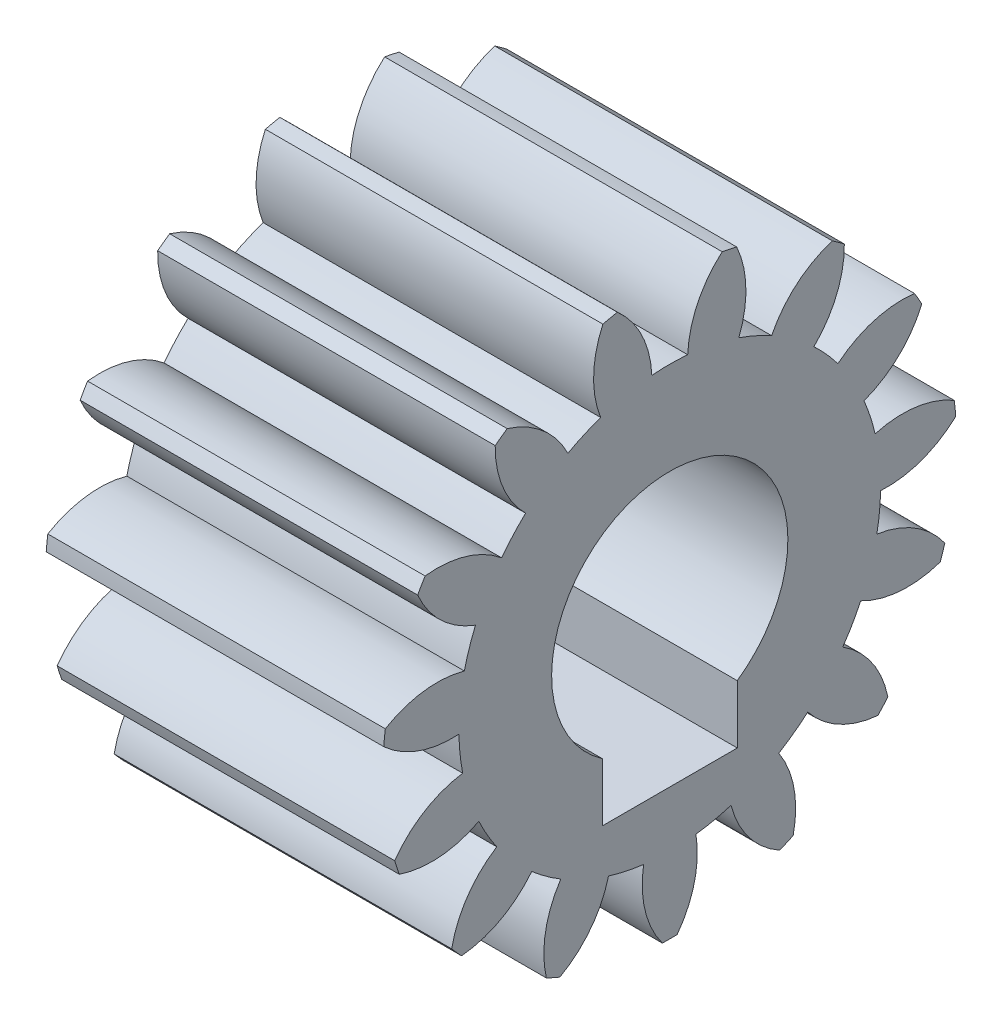
from build123d import *

# Parameters (mm, degrees)
BASPROSKE_W             = 5
BASPROSKE_H             = 4.25
TOOTHCUT_DEPTH          = 8.818247886
TEETHCUTS_COUNT         = 15
TEETHCUTS_ANGLE         = 336
BORSKE_R                = 0.5
BORE_DEPTH              = 50.0000508
SKETCH1_R               = 1.75
CUT_EXTRUDE1_DEPTH      = 8.811066965
CUT_EXTRUDE1_DEPTH_BACK = 8.811066965
SKETCH2_W               = 2
SKETCH2_H               = 1.1
CUT_EXTRUDE2_DEPTH      = 8.811066965
CUT_EXTRUDE2_DEPTH_BACK = 8.811066965


with BuildPart() as part:
    # BasProSke → Base-Revolve (revolve)
    with BuildSketch(Plane(origin=(0, 0, 0), x_dir=(1, 0, 0), z_dir=(0, 1, 0)), mode=Mode.PRIVATE) as base_revolve_sk:
        with Locations((2.5, 2.125)):
            Rectangle(BASPROSKE_W, BASPROSKE_H)
    revolve(base_revolve_sk.sketch.rotate(Axis((-10, 0, 0), (1, 0, 0)), 180), axis=Axis((-10, 0, 0), (1, 0, 0)))

    # TooCutSke → ToothCut (cut, through all)
    with BuildSketch(Plane(origin=(0, 0, 0), x_dir=(0, 0, -1), z_dir=(1, 0, 0))):
        with BuildLine():
            ThreePointArc((0.265767165, 3.112674704), (0, 3.124), (-0.265767165, 3.112674704))
            ThreePointArc((-0.265767165, 3.112674704), (-0.418628877, 3.712626775), (-0.800767345, 4.19974009))
            ThreePointArc((-0.800767345, 4.19974009), (0, 4.2754), (0.800767345, 4.19974009))
            ThreePointArc((0.800767345, 4.19974009), (0.418628877, 3.712626775), (0.265767165, 3.112674704))
        make_face()
    toothcut = extrude(amount=TOOTHCUT_DEPTH, mode=Mode.SUBTRACT)

    # TeethCuts: ToothCut ×15 about axis
    teethcuts_axis = Axis((-10, 0, 0), (1, 0, 0))
    for i in range(1, TEETHCUTS_COUNT):
        add(toothcut.rotate(teethcuts_axis, i * TEETHCUTS_ANGLE / (TEETHCUTS_COUNT - 1)), mode=Mode.SUBTRACT)

    # BorSke → Bore (cut, symmetric)
    with BuildSketch(Plane(origin=(0, 0, 0), x_dir=(0, 0, -1), z_dir=(1, 0, 0))):
        with Locations(Location((0, 0, 0), (0, 0, 180))):
            Circle(BORSKE_R)
    extrude(amount=BORE_DEPTH, both=True, mode=Mode.SUBTRACT)

    # Sketch1 → Cut-Extrude1 (cut, two sides)
    with BuildSketch(Plane(origin=(5, 0, 0), x_dir=(0, 0, -1), z_dir=(1, 0, 0))) as cut_extrude1_sk:
        Circle(SKETCH1_R)
    extrude(amount=CUT_EXTRUDE1_DEPTH, mode=Mode.SUBTRACT)
    extrude(cut_extrude1_sk.sketch, amount=-CUT_EXTRUDE1_DEPTH_BACK, mode=Mode.SUBTRACT)

    # Sketch2 → Cut-Extrude2 (cut, two sides)
    with BuildSketch(Plane(origin=(5, 0, 0), x_dir=(0, 0, -1), z_dir=(1, 0, 0))) as cut_extrude2_sk:
        with Locations((0, -1.75)):
            Rectangle(SKETCH2_W, SKETCH2_H)
    extrude(amount=CUT_EXTRUDE2_DEPTH, mode=Mode.SUBTRACT)
    extrude(cut_extrude2_sk.sketch, amount=-CUT_EXTRUDE2_DEPTH_BACK, mode=Mode.SUBTRACT)


solid = part.part
